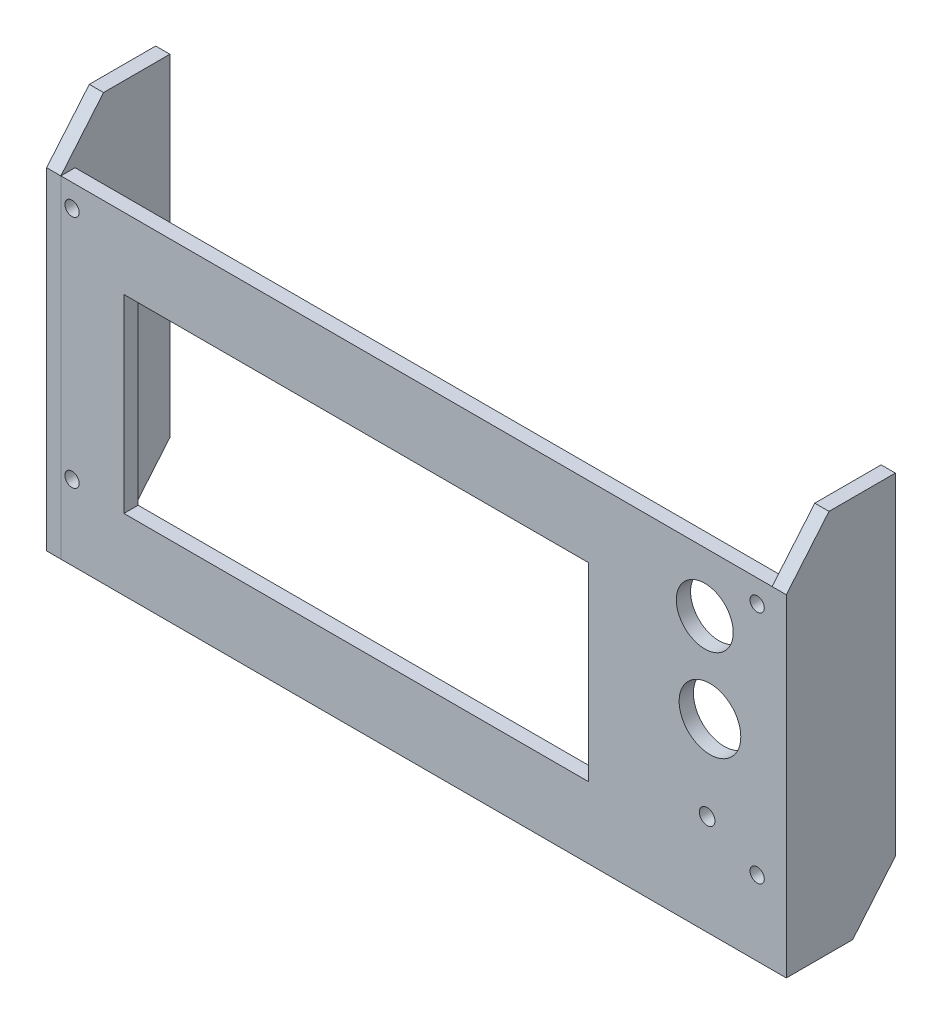
from build123d import *

# Parameters (mm, degrees)
CROQUIS1_W              = 150
CROQUIS1_H              = 70
CROQUIS1_R              = 6
SALIENTE_EXTRUIR1_DEPTH = 3
CROQUIS2_W              = 98
CROQUIS2_H              = 40
CORTAR_EXTRUIR1_DEPTH   = 3
CROQUIS3_R              = 6.5
CORTAR_EXTRUIR2_DEPTH   = 4
CROQUIS4_R              = 1.65
CORTAR_EXTRUIR3_DEPTH   = 3
CROQUIS5_R              = 1.5
CORTAR_EXTRUIR4_DEPTH   = 3
SALIENTE_EXTRUIR4_DEPTH = 3
CROQUIS9_W              = 3
CROQUIS9_H              = 70
SALIENTE_EXTRUIR5_DEPTH = 3


with BuildPart() as part:
    # Croquis1 → Saliente-Extruir1 (new body)
    with BuildSketch(Plane.XY):
        with Locations((75, 35)):
            Rectangle(CROQUIS1_W, CROQUIS1_H)
        with Locations((135.8, 57.5)):
            Circle(CROQUIS1_R, mode=Mode.SUBTRACT)
    extrude(amount=SALIENTE_EXTRUIR1_DEPTH)

    # Croquis2 → Cortar-Extruir1 (cut)
    with BuildSketch(Plane.XY.offset(3)):
        with Locations((62.3, 35)):
            Rectangle(CROQUIS2_W, CROQUIS2_H)
    extrude(amount=-CORTAR_EXTRUIR1_DEPTH, mode=Mode.SUBTRACT)

    # Croquis3 → Cortar-Extruir2 (cut, through all)
    with BuildSketch(Plane.XY.offset(3)):
        with Locations((136.9, 39.25)):
            Circle(CROQUIS3_R)
    extrude(amount=-CORTAR_EXTRUIR2_DEPTH, mode=Mode.SUBTRACT)

    # Croquis4 → Cortar-Extruir3 (cut)
    with BuildSketch(Plane.XY.offset(3)):
        with Locations((136.3, 21.15)):
            Circle(CROQUIS4_R)
    extrude(amount=-CORTAR_EXTRUIR3_DEPTH, mode=Mode.SUBTRACT)

    # Croquis5 → Cortar-Extruir4 (cut)
    with BuildSketch(Plane.XY.offset(3)):
        with Locations((146.85, 65.25)):
            Circle(CROQUIS5_R)
        with Locations((146.85, 15.75)):
            Circle(CROQUIS5_R)
        with Locations((2.35, 15.75)):
            Circle(CROQUIS5_R)
        with Locations((2.35, 65.25)):
            Circle(CROQUIS5_R)
    extrude(amount=-CORTAR_EXTRUIR4_DEPTH, mode=Mode.SUBTRACT)

    # Croquis7 → Saliente-Extruir4 (add)
    with BuildSketch(Plane(origin=(150, 0, 0), x_dir=(0, 0, -1), z_dir=(1, 0, 0))):
        Polygon((-3, 70), (6, 80.725782333), (20, 80.725782333), (20, 10.725782333), (11, 0), (-3, 0), align=None)
    extrude(amount=SALIENTE_EXTRUIR4_DEPTH)


with BuildPart() as body_2:
    # Croquis9 → Saliente-Extruir5 (new body)
    with BuildSketch(Plane.ZY):
        Polygon((-20, 80.725782333), (-6, 80.725782333), (3, 70), (0, 70), (0, 0), (-11, 0), (-20, 10.725782333), align=None)
        with Locations((1.5, 35)):
            Rectangle(CROQUIS9_W, CROQUIS9_H)
    extrude(amount=SALIENTE_EXTRUIR5_DEPTH)


solid = Compound([part.part, body_2.part])
